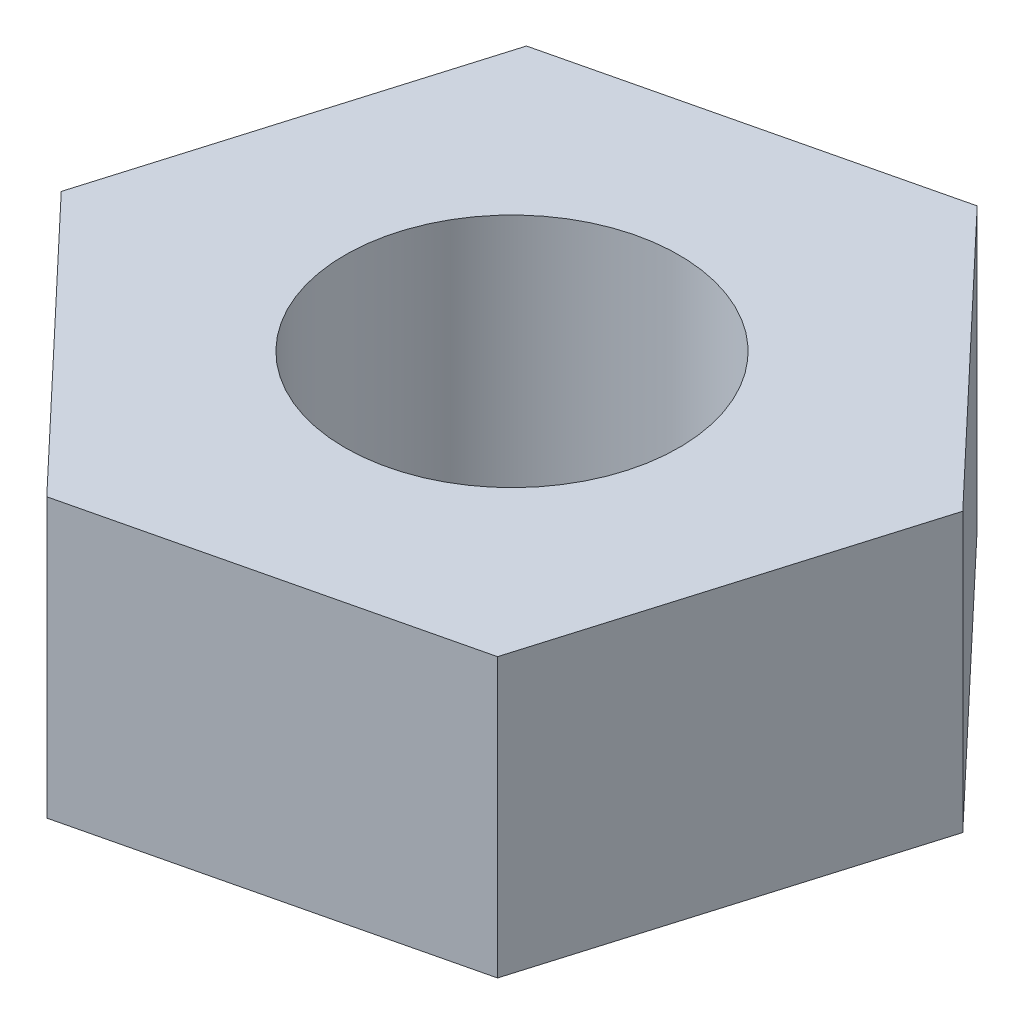
from build123d import *

# Parameters (mm, degrees)
BOSS_EXTRUDE1_DEPTH = 10
SKETCH2_R           = 6
CUT_EXTRUDE1_DEPTH  = 11


with BuildPart() as part:
    # Sketch1 → Boss-Extrude1 (new body)
    with BuildSketch(Plane(origin=(0, 0, 0), x_dir=(1, 0, 0), z_dir=(0, 1, 0))):
        Polygon((9.241553159, -9.761839175), (13.074777293, 3.122500219), (3.833224133, 12.884339394), (-9.241553159, 9.761839175), (-13.074777293, -3.122500219), (-3.833224133, -12.884339394), align=None)
    extrude(amount=BOSS_EXTRUDE1_DEPTH)

    # Sketch2 → Cut-Extrude1 (cut, through all)
    with BuildSketch(Plane(origin=(0, 10, 0), x_dir=(1, 0, 0), z_dir=(0, 1, 0))):
        Circle(SKETCH2_R)
    extrude(amount=-CUT_EXTRUDE1_DEPTH, mode=Mode.SUBTRACT)


solid = part.part
